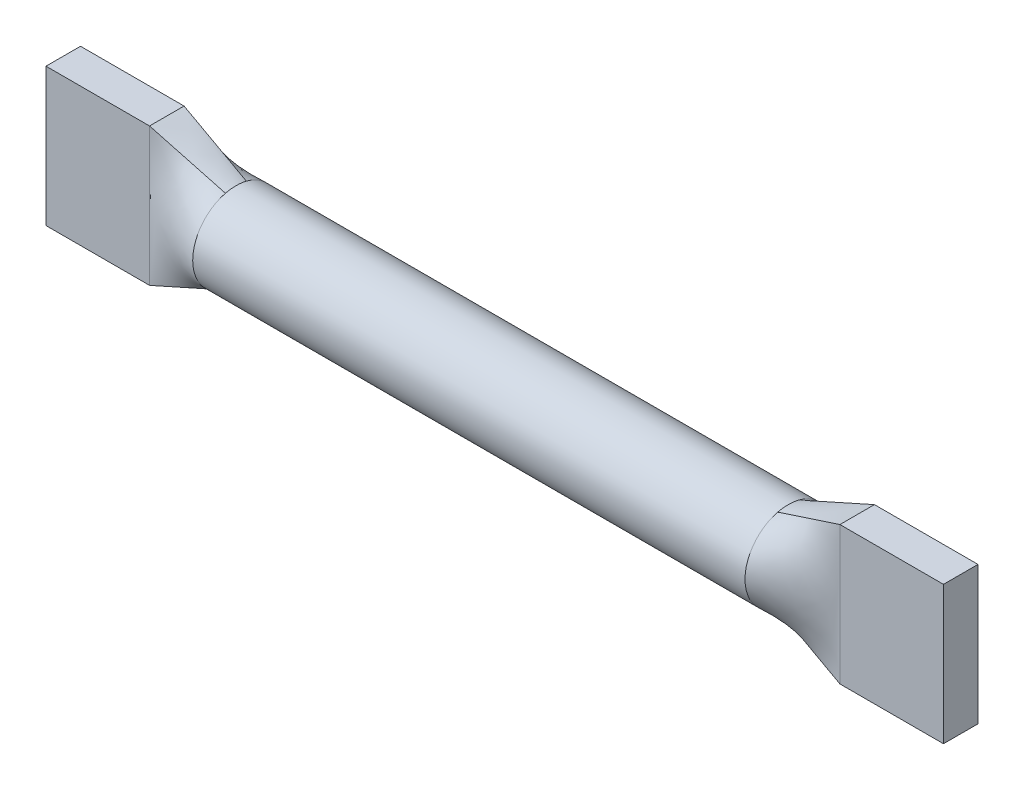
from build123d import *

# Parameters (mm, degrees)
SKETCH1_R           = 0.625
BOSS_EXTRUDE1_DEPTH = 4
SKETCH2_W           = 0.5
SKETCH2_H           = 2
SKETCH4_W           = 0.5
SKETCH4_H           = 2
BOSS_EXTRUDE2_DEPTH = 1.5


with BuildPart() as part:
    # Sketch1 → Boss-Extrude1 (new, symmetric)
    with BuildSketch(Plane(origin=(0, 0, 0), x_dir=(0, 0, -1), z_dir=(1, 0, 0))):
        Circle(SKETCH1_R)
    extrude(amount=BOSS_EXTRUDE1_DEPTH, both=True)

    # Sketch2 → Loft1 section 0
    with BuildSketch(Plane(origin=(5, 0, 0), x_dir=(0, 0, -1), z_dir=(1, 0, 0))):
        Rectangle(SKETCH2_W, SKETCH2_H)
    # Sketch3 for Loft1 → Loft1 section 1
    with BuildSketch(Plane(origin=(4, 0, 0), x_dir=(0, 0, -1), z_dir=(1, 0, 0))):
        with BuildLine():
            # circular arc as an exact rational Bezier (weights 1, cos(half-angle), 1)
            Bezier((0.151584766, -0.606339063), (0, -0.644235254), (-0.151584766, -0.606339063), weights=[1, 0.970142502, 1])
            Bezier((-0.151584766, -0.606339063), (-2.576941004, 0), (-0.151584766, 0.606339063), weights=[1, 0.242535626, 1])
            Bezier((-0.151584766, 0.606339063), (0, 0.644235254), (0.151584766, 0.606339063), weights=[1, 0.970142502, 1])
            Bezier((0.151584766, 0.606339063), (2.576941004, 0), (0.151584766, -0.606339063), weights=[1, 0.242535626, 1])
        make_face()
    loft1 = loft()

    # Sketch4 → Boss-Extrude2 (add)
    with BuildSketch(Plane(origin=(5, 0, 0), x_dir=(0, 0, -1), z_dir=(1, 0, 0))):
        Rectangle(SKETCH4_W, SKETCH4_H)
    boss_extrude2 = extrude(amount=BOSS_EXTRUDE2_DEPTH)

    # Mirror1: Loft1, Boss-Extrude2 across plane
    add(loft1.mirror(Plane(origin=(0, 0, 0), x_dir=(0, 0, 1), z_dir=(1, 0, 0))))
    add(boss_extrude2.mirror(Plane(origin=(0, 0, 0), x_dir=(0, 0, 1), z_dir=(1, 0, 0))))


solid = part.part
